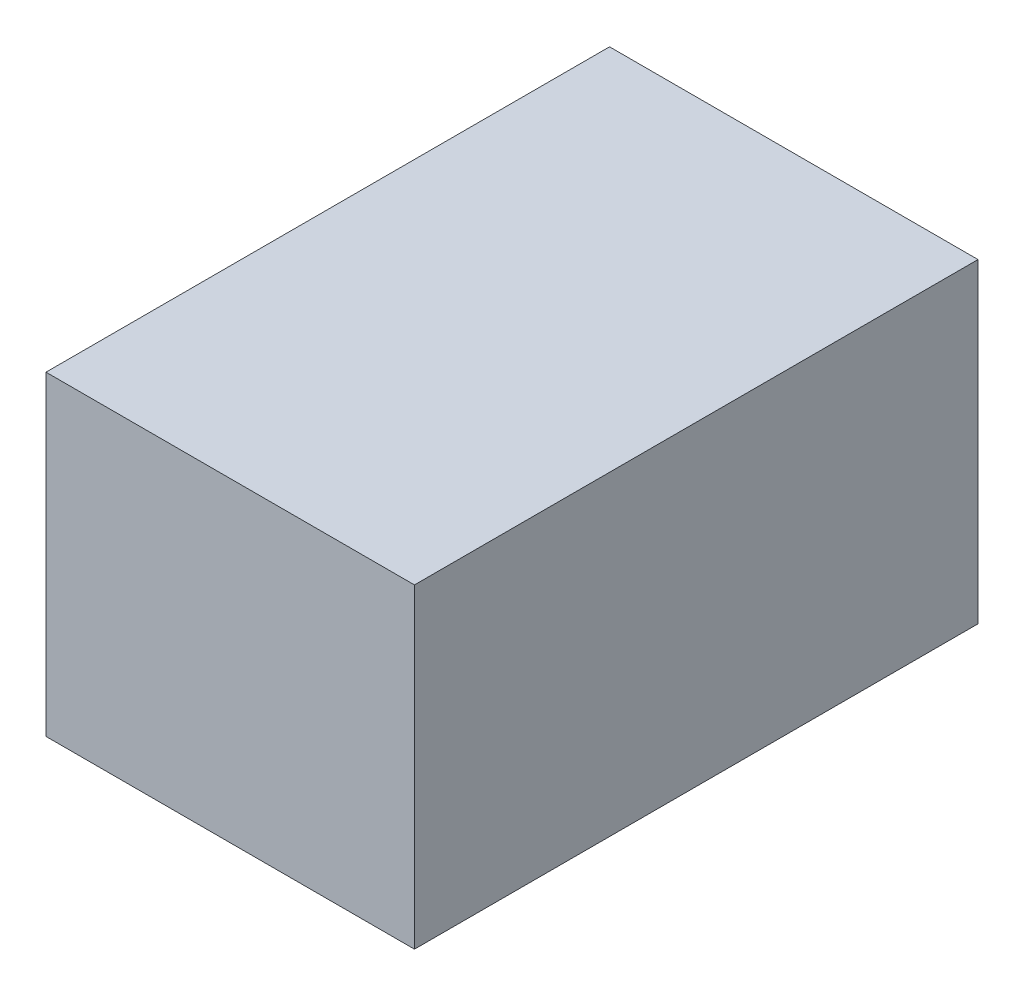
from build123d import *

# Parameters (mm, degrees)
SKETCH1_W           = 76.5
SKETCH1_H           = 117
BOSS_EXTRUDE1_DEPTH = 65.5


with BuildPart() as part:
    # Sketch1 → Boss-Extrude1 (new body)
    with BuildSketch(Plane(origin=(0, 0, 0), x_dir=(1, 0, 0), z_dir=(0, 1, 0))):
        with Locations((-1431.995508982, -291.068862275)):
            Rectangle(SKETCH1_W, SKETCH1_H)
    extrude(amount=BOSS_EXTRUDE1_DEPTH)


solid = part.part
